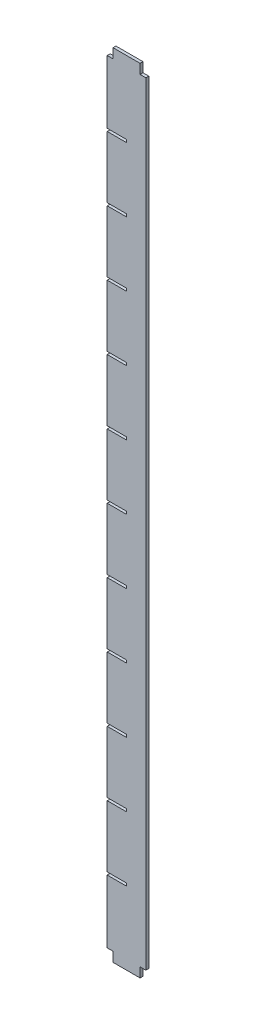
from build123d import *

# Parameters (mm, degrees)
SKETCH_1_W                 = 20
SKETCH_1_H                 = 410
EXTRUDE_1_DEPTH            = 1.5
CUT_EXTRUDE_1_REACH        = 3.5
SKETCH_2_W                 = 3
SKETCH_2_H                 = 5
SKETCH_3_W                 = 20
SKETCH_3_H                 = 1.4
CUT_EXTRUDE_2_DEPTH        = 1.5
PATTERN_LINEAR_1_COUNT     = 6
PATTERN_LINEAR_1_PITCH     = 33.33
PATTERN_LINEAR_1_COL_COUNT = 6
PATTERN_LINEAR_1_COL_PITCH = 33.33


with BuildPart() as part:
    # 草图1 → 凸台-拉伸1 (new body)
    with BuildSketch(Plane.XY):
        Rectangle(SKETCH_1_W, SKETCH_1_H)
    extrude(amount=EXTRUDE_1_DEPTH)

    # 草图2 → 切除-拉伸1 (cut, up to next)
    with BuildSketch(Plane.XY.offset(1.5), mode=Mode.PRIVATE) as cut_extrude_1_sk1:
        with Locations((-8.5, 202.5)):
            Rectangle(SKETCH_2_W, SKETCH_2_H)
    cut_extrude_1_tool1 = extrude(cut_extrude_1_sk1.sketch, amount=-CUT_EXTRUDE_1_REACH, mode=Mode.PRIVATE) & part.part
    add(cut_extrude_1_tool1.solids().sort_by_distance((-8.5, 202.5, 1.5))[0], mode=Mode.SUBTRACT)
    # 草图2 → 切除-拉伸1 (cut, up to next)
    with BuildSketch(Plane.XY.offset(1.5), mode=Mode.PRIVATE) as cut_extrude_1_sk2:
        with Locations((8.5, 202.5)):
            Rectangle(SKETCH_2_W, SKETCH_2_H)
    cut_extrude_1_tool2 = extrude(cut_extrude_1_sk2.sketch, amount=-CUT_EXTRUDE_1_REACH, mode=Mode.PRIVATE) & part.part
    add(cut_extrude_1_tool2.solids().sort_by_distance((8.5, 202.5, 1.5))[0], mode=Mode.SUBTRACT)
    # 草图2 → 切除-拉伸1 (cut, up to next)
    with BuildSketch(Plane.XY.offset(1.5), mode=Mode.PRIVATE) as cut_extrude_1_sk3:
        with Locations((-8.5, -202.5)):
            Rectangle(SKETCH_2_W, SKETCH_2_H)
    cut_extrude_1_tool3 = extrude(cut_extrude_1_sk3.sketch, amount=-CUT_EXTRUDE_1_REACH, mode=Mode.PRIVATE) & part.part
    add(cut_extrude_1_tool3.solids().sort_by_distance((-8.5, -202.5, 1.5))[0], mode=Mode.SUBTRACT)
    # 草图2 → 切除-拉伸1 (cut, up to next)
    with BuildSketch(Plane.XY.offset(1.5), mode=Mode.PRIVATE) as cut_extrude_1_sk4:
        with Locations((8.5, -202.5)):
            Rectangle(SKETCH_2_W, SKETCH_2_H)
    cut_extrude_1_tool4 = extrude(cut_extrude_1_sk4.sketch, amount=-CUT_EXTRUDE_1_REACH, mode=Mode.PRIVATE) & part.part
    add(cut_extrude_1_tool4.solids().sort_by_distance((8.5, -202.5, 1.5))[0], mode=Mode.SUBTRACT)

    # 草图3 → 切除-拉伸2 (cut)
    with BuildSketch(Plane.XY.offset(1.5)):
        with Locations((-10, 0)):
            Rectangle(SKETCH_3_W, SKETCH_3_H)
    cut_extrude_2 = extrude(amount=-CUT_EXTRUDE_2_DEPTH, mode=Mode.SUBTRACT)

    # 阵列(线性)1: 切除-拉伸2 ×6
    with Locations(*[(0, i * PATTERN_LINEAR_1_PITCH, 0) for i in range(1, PATTERN_LINEAR_1_COUNT)]):
        add(cut_extrude_2, mode=Mode.SUBTRACT)

    # 阵列(线性)1 col: 切除-拉伸2 ×6
    with Locations(*[(0, -i * PATTERN_LINEAR_1_COL_PITCH, 0) for i in range(1, PATTERN_LINEAR_1_COL_COUNT)]):
        add(cut_extrude_2, mode=Mode.SUBTRACT)


solid = part.part
